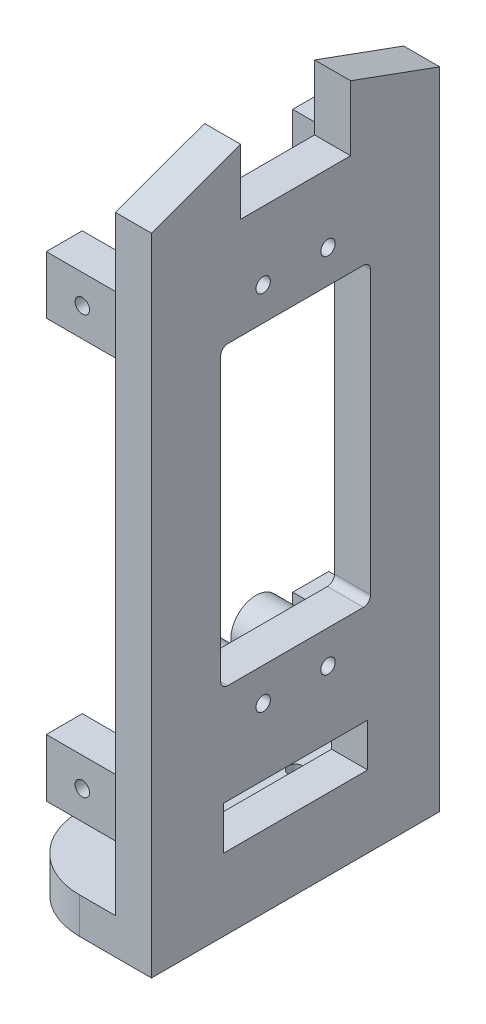
from build123d import *

# Parameters (mm, degrees)
SKETCH1_R           = 1
BOSS_EXTRUDE1_DEPTH = 5
SKETCH2_W           = 5
SKETCH2_H           = 40
BOSS_EXTRUDE2_DEPTH = 80
SKETCH3_R           = 2.22
CUT_EXTRUDE3_DEPTH  = 80
SKETCH5_R           = 2.22
SKETCH5_R_2         = 1
BOSS_EXTRUDE3_DEPTH = 10
SKETCH6_R           = 3.5
SKETCH6_R_2         = 2.22
BOSS_EXTRUDE4_DEPTH = 5
SKETCH7_W           = 18.8
SKETCH7_H           = 4.557781783
CUT_EXTRUDE4_DEPTH  = 10
BOSS_EXTRUDE5_DEPTH = 5
SKETCH9_W           = 20
SKETCH9_H           = 6
CUT_EXTRUDE7_DEPTH  = 10
SKETCH10_W          = 5
SKETCH10_H          = 8
BOSS_EXTRUDE6_DEPTH = 10
SKETCH11_R          = 1
CUT_EXTRUDE9_DEPTH  = 8
SKETCH12_R          = 1
CUT_EXTRUDE10_DEPTH = 8


with BuildPart() as part:
    # Sketch1 → Boss-Extrude1 (new body)
    with BuildSketch(Plane(origin=(0, 0, 0), x_dir=(1, 0, 0), z_dir=(0, 1, 0))):
        with BuildLine():
            Line((5.319641756, -11.332905968), (15.319641756, -11.332905968))
            Line((15.319641756, -11.332905968), (15.319641756, 28.667094032))
            Line((15.319641756, 28.667094032), (5.319641756, 28.667094032))
            ThreePointArc((5.319641756, 28.667094032), (-1.751426056, 25.738161844), (-4.680358244, 18.667094032))
            Line((-4.680358244, 18.667094032), (-4.680358244, -1.332905968))
            ThreePointArc((-4.680358244, -1.332905968), (-1.751426056, -8.40397378), (5.319641756, -11.332905968))
        make_face()
        with Locations((5.319641756, 18.667094032)):
            Circle(SKETCH1_R, mode=Mode.SUBTRACT)
        with Locations((5.319641756, -1.332905968)):
            Circle(SKETCH1_R, mode=Mode.SUBTRACT)
    extrude(amount=BOSS_EXTRUDE1_DEPTH)

    # Sketch2 → Boss-Extrude2 (add)
    with BuildSketch(Plane(origin=(0, 5, 0), x_dir=(1, 0, 0), z_dir=(0, 1, 0))):
        with Locations((12.819641756, 8.667094032)):
            Rectangle(SKETCH2_W, SKETCH2_H)
    extrude(amount=BOSS_EXTRUDE2_DEPTH)

    # Sketch3 → Cut-Extrude3 (cut)
    with BuildSketch(Plane.ZY.offset(-10.319641756)):
        with BuildLine():
            ThreePointArc((0.732905968, 35.401978793), (1.440012749, 35.694872012), (1.732905968, 36.401978793))
            Line((1.732905968, 36.401978793), (1.732905968, 69.94419701))
            ThreePointArc((1.732905968, 69.94419701), (1.440012749, 70.651303792), (0.732905968, 70.94419701))
            Line((0.732905968, 70.94419701), (-18.067094032, 70.94419701))
            ThreePointArc((-18.067094032, 70.94419701), (-18.774200813, 70.651303792), (-19.067094032, 69.94419701))
            Line((-19.067094032, 69.94419701), (-19.067094032, 36.401978793))
            ThreePointArc((-19.067094032, 36.401978793), (-18.774200813, 35.694872012), (-18.067094032, 35.401978793))
            Line((-18.067094032, 35.401978793), (0.732905968, 35.401978793))
        make_face()
        with Locations((-13.167094032, 75.54419701)):
            Circle(SKETCH3_R)
        with Locations((-13.167094032, 25.24419701)):
            Circle(SKETCH3_R)
        with Locations((-4.167094032, 25.24419701)):
            Circle(SKETCH3_R)
        with Locations((-4.167094032, 75.54419701)):
            Circle(SKETCH3_R)
    extrude(amount=-CUT_EXTRUDE3_DEPTH, mode=Mode.SUBTRACT)

    # Sketch5 → Boss-Extrude3 (add)
    with BuildSketch(Plane(origin=(15.319641756, 0, 0), x_dir=(0, 0, -1), z_dir=(1, 0, 0))):
        with Locations((4.167094032, 25.24419701)):
            Circle(SKETCH5_R)
        with Locations((4.167094032, 25.24419701)):
            Circle(SKETCH5_R_2, mode=Mode.SUBTRACT)
        with Locations((13.167094032, 25.24419701)):
            Circle(SKETCH5_R)
        with Locations((13.167094032, 25.24419701)):
            Circle(SKETCH5_R_2, mode=Mode.SUBTRACT)
        with Locations((4.167094032, 75.54419701)):
            Circle(SKETCH5_R)
        with Locations((4.167094032, 75.54419701)):
            Circle(SKETCH5_R_2, mode=Mode.SUBTRACT)
        with Locations((13.167094032, 75.54419701)):
            Circle(SKETCH5_R)
        with Locations((13.167094032, 75.54419701)):
            Circle(SKETCH5_R_2, mode=Mode.SUBTRACT)
    extrude(amount=-BOSS_EXTRUDE3_DEPTH)

    # Sketch6 → Boss-Extrude4 (add)
    with BuildSketch(Plane.ZY.offset(-10.319641756)):
        with Locations((-4.167094032, 25.24419701)):
            Circle(SKETCH6_R)
        with Locations((-4.167094032, 25.24419701)):
            Circle(SKETCH6_R_2, mode=Mode.SUBTRACT)
        with Locations((-13.167094032, 25.24419701)):
            Circle(SKETCH6_R)
        with Locations((-13.167094032, 25.24419701)):
            Circle(SKETCH6_R_2, mode=Mode.SUBTRACT)
        with Locations((-4.167094032, 75.54419701)):
            Circle(SKETCH6_R)
        with Locations((-4.167094032, 75.54419701)):
            Circle(SKETCH6_R_2, mode=Mode.SUBTRACT)
        with Locations((-13.167094032, 75.54419701)):
            Circle(SKETCH6_R)
        with Locations((-13.167094032, 75.54419701)):
            Circle(SKETCH6_R_2, mode=Mode.SUBTRACT)
    extrude(amount=BOSS_EXTRUDE4_DEPTH)

    # Sketch7 → Cut-Extrude4 (cut)
    with BuildSketch(Plane.ZY.offset(-10.319641756)):
        with BuildLine():
            ThreePointArc((1.732905968, 36.401978793), (1.627333159, 35.954765198), (1.332905968, 35.601978793))
            Line((1.332905968, 35.601978793), (1.332905968, 30.84419701))
            ThreePointArc((1.332905968, 30.84419701), (1.157170037, 30.419932942), (0.732905968, 30.24419701))
            Line((0.732905968, 30.24419701), (-18.067094032, 30.24419701))
            ThreePointArc((-18.067094032, 30.24419701), (-18.491358101, 30.419932942), (-18.667094032, 30.84419701))
            Line((-18.667094032, 30.84419701), (-18.667094032, 35.601978793))
            ThreePointArc((-18.667094032, 35.601978793), (-18.961521223, 35.954765198), (-19.067094032, 36.401978793))
            Line((-19.067094032, 36.401978793), (-19.067094032, 30.84419701))
            ThreePointArc((-19.067094032, 30.84419701), (-18.774200813, 30.137090229), (-18.067094032, 29.84419701))
            Line((-18.067094032, 29.84419701), (0.732905968, 29.84419701))
            ThreePointArc((0.732905968, 29.84419701), (1.440012749, 30.137090229), (1.732905968, 30.84419701))
            Line((1.732905968, 30.84419701), (1.732905968, 36.401978793))
        make_face()
        with BuildLine():
            Line((1.332905968, 30.84419701), (1.332905968, 35.601978793))
            ThreePointArc((1.332905968, 35.601978793), (1.049133734, 35.453295495), (0.732905968, 35.401978793))
            Line((0.732905968, 35.401978793), (0.732905968, 30.84419701))
            Line((0.732905968, 30.84419701), (-18.067094032, 30.84419701))
            Line((-18.067094032, 30.84419701), (-18.067094032, 35.401978793))
            ThreePointArc((-18.067094032, 35.401978793), (-18.383321798, 35.453295495), (-18.667094032, 35.601978793))
            Line((-18.667094032, 35.601978793), (-18.667094032, 30.84419701))
            ThreePointArc((-18.667094032, 30.84419701), (-18.491358101, 30.419932942), (-18.067094032, 30.24419701))
            Line((-18.067094032, 30.24419701), (0.732905968, 30.24419701))
            ThreePointArc((0.732905968, 30.24419701), (1.157170037, 30.419932942), (1.332905968, 30.84419701))
        make_face()
        with Locations((-8.667094032, 33.123087901)):
            Rectangle(SKETCH7_W, SKETCH7_H)
    extrude(amount=-CUT_EXTRUDE4_DEPTH, mode=Mode.SUBTRACT)

    # Sketch8 → Boss-Extrude5 (add, through all)
    with BuildSketch(Plane.ZY.offset(-10.319641756)):
        Polygon((-28.667094032, 89.50779106), (-28.667094032, 85), (-16.300533883, 85), (-16.300533883, 94.015582119), align=None)
        Polygon((-1.033654181, 94.015582119), (-1.033654181, 85), (11.332905968, 85), (11.332905968, 89.50779106), align=None)
    extrude(amount=-BOSS_EXTRUDE5_DEPTH)

    # Sketch9 → Cut-Extrude7 (cut)
    with BuildSketch(Plane.ZY.offset(-10.319641756)):
        with Locations((-8.667094032, 13)):
            Rectangle(SKETCH9_W, SKETCH9_H)
    extrude(amount=-CUT_EXTRUDE7_DEPTH, mode=Mode.SUBTRACT)

    # Sketch10 → Boss-Extrude6 (add)
    with BuildSketch(Plane.ZY.offset(-10.319641756)):
        with Locations((-25.767094032, 17.566871705)):
            Rectangle(SKETCH10_W, SKETCH10_H)
        with Locations((8.432905968, 17.566871705)):
            Rectangle(SKETCH10_W, SKETCH10_H)
        with Locations((8.432905968, 75.6)):
            Rectangle(SKETCH10_W, SKETCH10_H)
        with Locations((-25.767094032, 75.6)):
            Rectangle(SKETCH10_W, SKETCH10_H)
    extrude(amount=BOSS_EXTRUDE6_DEPTH)

    # Sketch11 → Cut-Extrude9 (cut)
    with BuildSketch(Plane.XY.offset(10.932905968)):
        with Locations((5.319641756, 17.566871705)):
            Circle(SKETCH11_R)
        with Locations((5.319641756, 75.6)):
            Circle(SKETCH11_R)
    extrude(amount=-CUT_EXTRUDE9_DEPTH, mode=Mode.SUBTRACT)

    # Sketch12 → Cut-Extrude10 (cut)
    with BuildSketch(Plane(origin=(0, 0, -28.267094032), x_dir=(-1, 0, 0), z_dir=(0, 0, -1))):
        with Locations((-5.319641756, 75.6)):
            Circle(SKETCH12_R)
        with Locations((-5.319641756, 17.566871705)):
            Circle(SKETCH12_R)
    extrude(amount=-CUT_EXTRUDE10_DEPTH, mode=Mode.SUBTRACT)


solid = part.part
